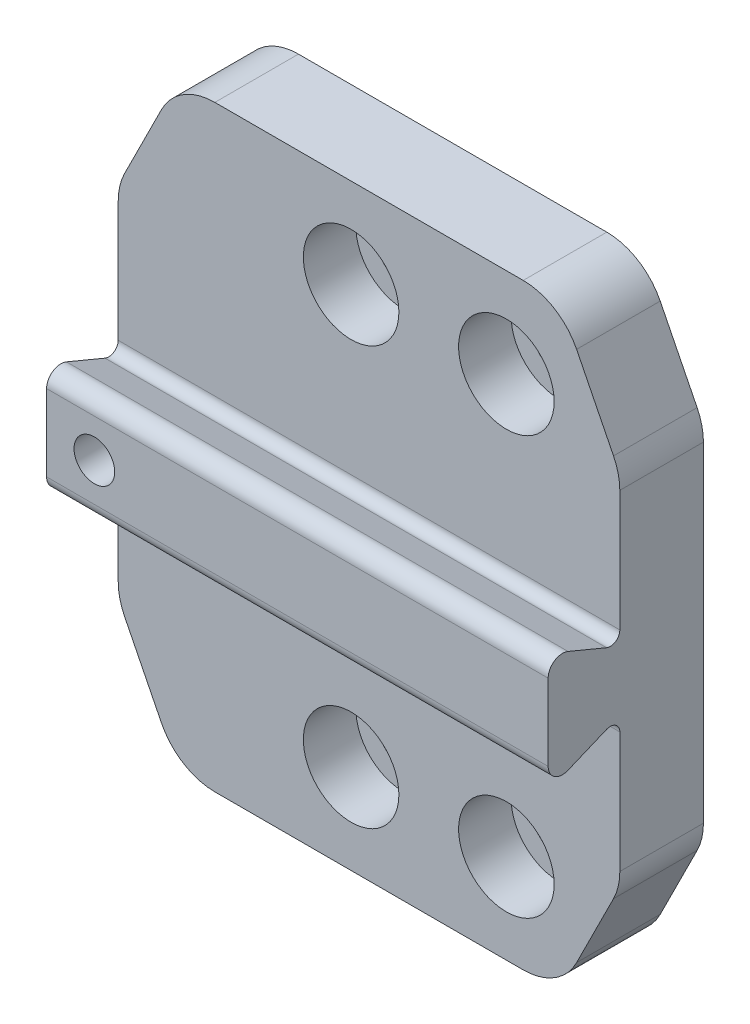
from build123d import *

# Parameters (mm, degrees)
SKIZZE1_W                                            = 42
SKIZZE1_H                                            = 50
AUFSATZ_LINEAR_AUSTRAGEN1_DEPTH                      = 7
STIRNSENKUNG_F_R_M4_ZYLINDERSCHRAUBE_MIT_D           = 4.5
STIRNSENKUNG_F_R_M4_ZYLINDERSCHRAUBE_MIT_CBORE_D     = 8
STIRNSENKUNG_F_R_M4_ZYLINDERSCHRAUBE_MIT_CBORE_DEPTH = 4.4
AUFSATZ_LINEAR_AUSTRAGEN2_DEPTH                      = 42
VERRUNDUNG1_R                                        = 0.8
SCHNITT_LINEAR_AUSTRAGEN1_DEPTH                      = 14
VERRUNDUNG2_R                                        = 5
VERRUNDUNG3_R                                        = 1.2
STIRNSENKUNG_F_R_M3_ZYLINDERSCHRAUBE_MIT_D           = 3.4
STIRNSENKUNG_F_R_M3_ZYLINDERSCHRAUBE_MIT_CBORE_D     = 6.5
STIRNSENKUNG_F_R_M3_ZYLINDERSCHRAUBE_MIT_CBORE_DEPTH = 3.4


with BuildPart() as part:
    # Skizze1 → Aufsatz-Linear austragen1 (new body)
    with BuildSketch(Plane.XY):
        Rectangle(SKIZZE1_W, SKIZZE1_H)
    extrude(amount=AUFSATZ_LINEAR_AUSTRAGEN1_DEPTH)

    # Stirnsenkung für M4 Zylinderschraube mit Innensechskant1 (through all)
    with Locations(Plane.XY.offset(7)):
        with Locations((-1.5, 17.5), (11.5, 17.5), (11.5, -17.5), (-1.5, -17.5)):
            CounterBoreHole(STIRNSENKUNG_F_R_M4_ZYLINDERSCHRAUBE_MIT_D / 2, STIRNSENKUNG_F_R_M4_ZYLINDERSCHRAUBE_MIT_CBORE_D / 2, STIRNSENKUNG_F_R_M4_ZYLINDERSCHRAUBE_MIT_CBORE_DEPTH)

    # Skizze4 → Aufsatz-Linear austragen2 (add, through all)
    with BuildSketch(Plane(origin=(21, 0, 0), x_dir=(0, 0, -1), z_dir=(1, 0, 0))):
        Polygon((-7, 2.5), (-13, 5), (-13, -5), (-7, -2.5), align=None)
    extrude(amount=-AUFSATZ_LINEAR_AUSTRAGEN2_DEPTH)

    # Verrundung1
    verrundung1_edges = [part.edges().sort_by_distance(p)[0] for p in [
        (0, 2.5, 7),
        (0, -2.5, 7),
    ]]
    fillet(verrundung1_edges, radius=VERRUNDUNG1_R)

    # Skizze5 → Schnitt-Linear austragen1 (cut, through all)
    with BuildSketch(Plane(origin=(0, 0, 0), x_dir=(-1, 0, 0), z_dir=(0, 0, -1))):
        Polygon((-21, 25), (-21, 15), (-16, 25), align=None)
        Polygon((21, 25), (16, 25), (21, 15), align=None)
        Polygon((-21, -15), (-21, -25), (-16, -25), align=None)
        Polygon((16, -25), (21, -25), (21, -15), align=None)
    extrude(amount=-SCHNITT_LINEAR_AUSTRAGEN1_DEPTH, mode=Mode.SUBTRACT)

    # Verrundung2
    verrundung2_edges = [part.edges().sort_by_distance(p)[0] for p in [
        (16, 25, 3.5),
        (21, 15, 3.5),
        (-21, 15, 3.5),
        (-16, 25, 3.5),
        (21, -15, 3.5),
        (16, -25, 3.5),
        (-16, -25, 3.5),
        (-21, -15, 3.5),
    ]]
    fillet(verrundung2_edges, radius=VERRUNDUNG2_R)

    # Verrundung3
    verrundung3_edges = [part.edges().sort_by_distance(p)[0] for p in [
        (0, -5, 13),
        (0, 5, 13),
    ]]
    fillet(verrundung3_edges, radius=VERRUNDUNG3_R)

    # Stirnsenkung für M3 Zylinderschraube mit Innensechskant1 (through all)
    with Locations(Plane(origin=(0, 0, 0), x_dir=(-1, 0, 0), z_dir=(0, 0, -1))):
        with Locations((17, 0)):
            CounterBoreHole(STIRNSENKUNG_F_R_M3_ZYLINDERSCHRAUBE_MIT_D / 2, STIRNSENKUNG_F_R_M3_ZYLINDERSCHRAUBE_MIT_CBORE_D / 2, STIRNSENKUNG_F_R_M3_ZYLINDERSCHRAUBE_MIT_CBORE_DEPTH)


solid = part.part
